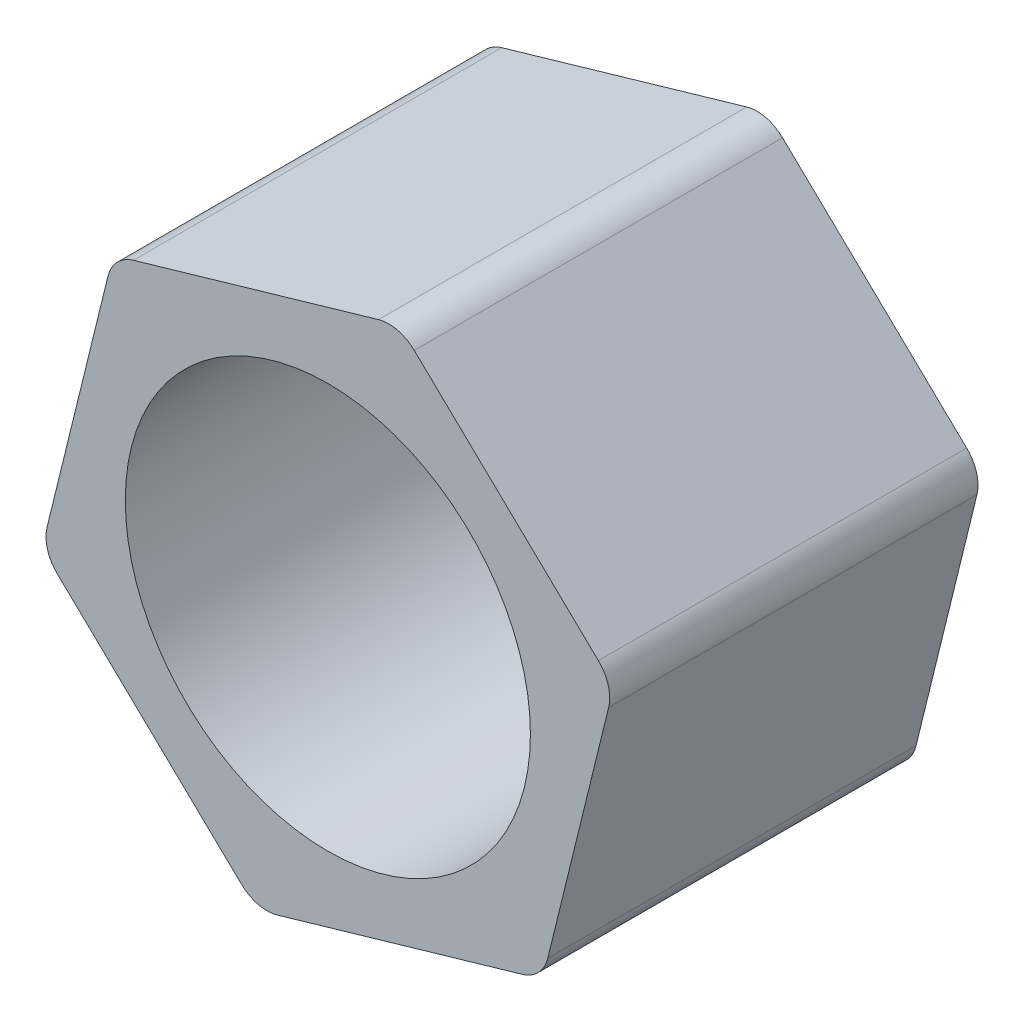
from build123d import *

# Parameters (mm, degrees)
SKETCH3_R           = 11
BOSS_EXTRUDE1_DEPTH = 20
FILLET1_R           = 2


with BuildPart() as part:
    # Sketch3 → Boss-Extrude1 (new body)
    with BuildSketch(Plane.XY):
        Polygon((11.666242226, -11.190716048), (15.524565497, 4.50790411), (3.858323271, 15.698620158), (-11.666242226, 11.190716048), (-15.524565497, -4.50790411), (-3.858323271, -15.698620158), align=None)
        Circle(SKETCH3_R, mode=Mode.SUBTRACT)
    extrude(amount=BOSS_EXTRUDE1_DEPTH)

    # Fillet1
    fillet1_edges = [part.edges().sort_by_distance(p)[0] for p in [
        (-3.858323271, -15.698620158, 10),
        (-15.524565497, -4.50790411, 10),
        (-11.666242226, 11.190716048, 10),
        (3.858323271, 15.698620158, 10),
        (15.524565497, 4.50790411, 10),
        (11.666242226, -11.190716048, 10),
    ]]
    fillet(fillet1_edges, radius=FILLET1_R)


solid = part.part
